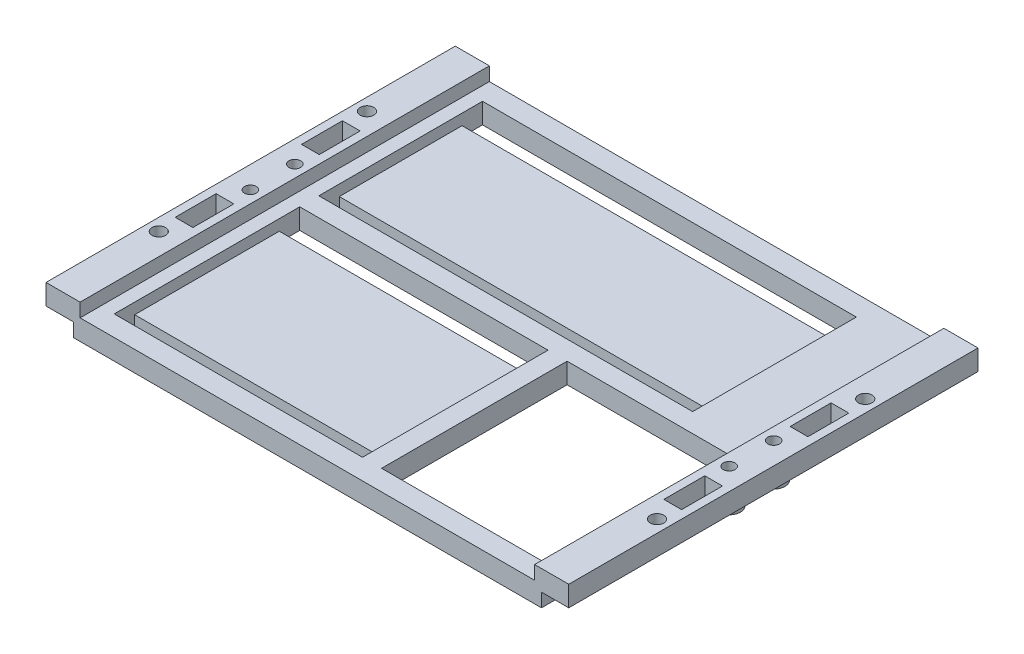
from build123d import *

# Parameters (mm, degrees)
PLATEFRAME_DEPTH          = 150
SKETCH3_R                 = 2.5
HOLESUPPORT_DEPTH         = 13.5
SKETCH4_R                 = 4.15
SKETCH4_R_2               = 2.15
CYLINDRICALSUPPORTS_DEPTH = 12.5
SKETCH8_W                 = 137
SKETCH8_H                 = 60
SKETCH8_W_2               = 91
SKETCH8_H_2               = 68
ITEMLAYOUT_DEPTH          = 4
SKETCH9_W                 = 58.6
SKETCH9_H                 = 68
HOLECUTOUT_DEPTH          = 7.5
SKETCH10_W                = 91
SKETCH10_H                = 7.5
SKETCH10_W_2              = 137
VELCROCUT_DEPTH           = 3.5
SKETCH11_W                = 6.5
SKETCH11_H                = 15
CUTSHELLHOLES_DEPTH       = 12.5
SKETCH12_R                = 2.5
STANDOFFHOLES_DEPTH       = 13.5
SKETCH13_W                = 2.5
SKETCH13_H                = 41
CUTSTANDOFFROOM_DEPTH     = 5


with BuildPart() as part:
    # Sketch2 → PlateFrame (new body)
    with BuildSketch(Plane.XY):
        Polygon((179.1, 12.5), (191.6, 12.5), (191.6, 5), (184.1, 5), (184.1, 0), (7.5, 0), (7.5, 5), (0, 5), (0, 12.5), (12.5, 12.5), (12.5, 7.5), (179.1, 7.5), align=None)
    extrude(amount=PLATEFRAME_DEPTH)

    # Sketch3 → HoleSupport (cut, through all)
    with BuildSketch(Plane(origin=(0, 12.5, 0), x_dir=(1, 0, 0), z_dir=(0, 1, 0))):
        with Locations((8.05, -66.85)):
            Circle(SKETCH3_R)
        with Locations((8.05, -83.15)):
            Circle(SKETCH3_R)
        with Locations((183.55, -66.85)):
            Circle(SKETCH3_R)
        with Locations((183.55, -83.15)):
            Circle(SKETCH3_R)
    extrude(amount=-HOLESUPPORT_DEPTH, mode=Mode.SUBTRACT)

    # Sketch4 → CylindricalSupports (add)
    with BuildSketch(Plane(origin=(0, 12.5, 0), x_dir=(1, 0, 0), z_dir=(0, 1, 0))):
        with Locations((183.55, -66.85)):
            Circle(SKETCH4_R)
        with Locations((183.55, -66.85)):
            Circle(SKETCH4_R_2, mode=Mode.SUBTRACT)
        with Locations((183.55, -83.15)):
            Circle(SKETCH4_R)
        with Locations((183.55, -83.15)):
            Circle(SKETCH4_R_2, mode=Mode.SUBTRACT)
        with Locations((8.05, -66.85)):
            Circle(SKETCH4_R)
        with Locations((8.05, -66.85)):
            Circle(SKETCH4_R_2, mode=Mode.SUBTRACT)
        with Locations((8.05, -83.15)):
            Circle(SKETCH4_R)
        with Locations((8.05, -83.15)):
            Circle(SKETCH4_R_2, mode=Mode.SUBTRACT)
    extrude(amount=-CYLINDRICALSUPPORTS_DEPTH)

    # Sketch8 → ItemLayout (cut)
    with BuildSketch(Plane(origin=(0, 7.5, 0), x_dir=(1, 0, 0), z_dir=(0, 1, 0))):
        with Locations((86, -37.5)):
            Rectangle(SKETCH8_W, SKETCH8_H)
        with Locations((63, -108.5)):
            Rectangle(SKETCH8_W_2, SKETCH8_H_2)
    extrude(amount=-ITEMLAYOUT_DEPTH, mode=Mode.SUBTRACT)

    # Sketch9 → HoleCutout (cut)
    with BuildSketch(Plane(origin=(0, 7.5, 0), x_dir=(1, 0, 0), z_dir=(0, 1, 0))):
        with Locations((144.8, -108.5)):
            Rectangle(SKETCH9_W, SKETCH9_H)
    extrude(amount=-HOLECUTOUT_DEPTH, mode=Mode.SUBTRACT)

    # Sketch10 → VelcroCut (cut)
    with BuildSketch(Plane(origin=(0, 3.5, 0), x_dir=(1, 0, 0), z_dir=(0, 1, 0))):
        with Locations((63, -78.25)):
            Rectangle(SKETCH10_W, SKETCH10_H)
        with Locations((63, -138.75)):
            Rectangle(SKETCH10_W, SKETCH10_H)
        with Locations((86, -11.25)):
            Rectangle(SKETCH10_W_2, SKETCH10_H)
        with Locations((86, -63.75)):
            Rectangle(SKETCH10_W_2, SKETCH10_H)
    extrude(amount=-VELCROCUT_DEPTH, mode=Mode.SUBTRACT)

    # Sketch11 → CutShellHoles (cut)
    with BuildSketch(Plane(origin=(0, 12.5, 0), x_dir=(1, 0, 0), z_dir=(0, 1, 0))):
        with Locations((6.25, -51.85)):
            Rectangle(SKETCH11_W, SKETCH11_H)
        with Locations((185.35, -51.85)):
            Rectangle(SKETCH11_W, SKETCH11_H)
        with Locations((185.35, -98.15)):
            Rectangle(SKETCH11_W, SKETCH11_H)
        with Locations((6.25, -98.15)):
            Rectangle(SKETCH11_W, SKETCH11_H)
    extrude(amount=-CUTSHELLHOLES_DEPTH, mode=Mode.SUBTRACT)

    # Sketch12 → StandoffHoles (cut, through all)
    with BuildSketch(Plane(origin=(0, 12.5, 0), x_dir=(1, 0, 0), z_dir=(0, 1, 0))):
        with Locations((4.5, -36.85)):
            Circle(SKETCH12_R)
        with Locations((4.5, -113.15)):
            Circle(SKETCH12_R)
        with Locations((187.1, -36.85)):
            Circle(SKETCH12_R)
        with Locations((187.1, -113.15)):
            Circle(SKETCH12_R)
    extrude(amount=-STANDOFFHOLES_DEPTH, mode=Mode.SUBTRACT)

    # Sketch13 → CutStandoffRoom (cut)
    with BuildSketch(Plane.XZ):
        with Locations((8.75, 20.5)):
            Rectangle(SKETCH13_W, SKETCH13_H)
        with Locations((8.75, 129.5)):
            Rectangle(SKETCH13_W, SKETCH13_H)
        with Locations((182.85, 129.5)):
            Rectangle(SKETCH13_W, SKETCH13_H)
        with Locations((182.85, 20.5)):
            Rectangle(SKETCH13_W, SKETCH13_H)
    extrude(amount=-CUTSTANDOFFROOM_DEPTH, mode=Mode.SUBTRACT)


solid = part.part
